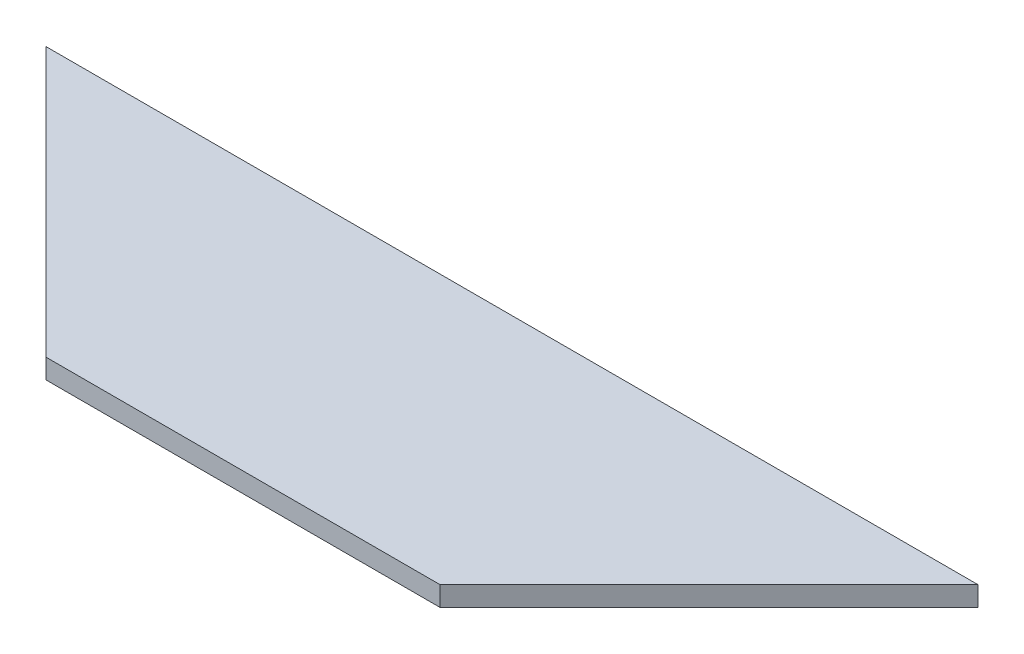
from build123d import *

# Parameters (mm, degrees)
BOSS_EXTRUDE1_DEPTH = 19.05


with BuildPart() as part:
    # Sketch1 → Boss-Extrude1 (new body)
    with BuildSketch(Plane(origin=(0, 0, 0), x_dir=(1, 0, 0), z_dir=(0, 1, 0))):
        Polygon((0, 0), (900, 0), (640.26296725, -259.73703275), (259.73703275, -259.73703275), align=None)
    extrude(amount=BOSS_EXTRUDE1_DEPTH)


solid = part.part
